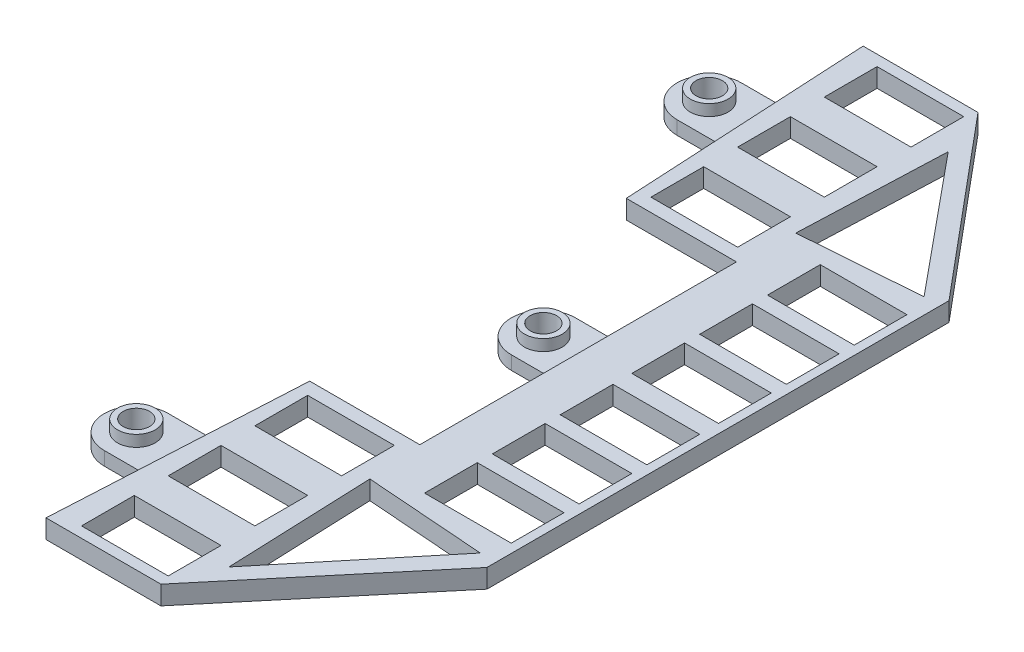
from build123d import *

# Parameters (mm, degrees)
RESSALTO_EXTRUS_O1_DEPTH         = 1.25
ESBO_O5_W                        = 11.5
ESBO_O5_H                        = 7
CORTE_EXTRUS_O1_DEPTH            = 2.5
PADR_O_LINEAR1_COUNT             = 3
PADR_O_LINEAR1_PITCH             = 9
ESBO_O8_W                        = 11.5
ESBO_O8_H                        = 7
CORTE_EXTRUS_O4_DEPTH            = 10
PADR_O_LINEAR3_COUNT             = 3
PADR_O_LINEAR3_PITCH             = 11.5
ESPELHAR1_COPY_1_SKETCH_W        = 11.5
ESPELHAR1_COPY_1_SKETCH_H        = 7
ESPELHAR1_COPY_1_DEPTH           = 10
ESPELHAR1_COPY_2_SKETCH_W        = 11.5
ESPELHAR1_COPY_2_SKETCH_H        = 7
ESPELHAR1_COPY_2_DEPTH           = 10
ESPELHAR2_COPY_1_SKETCH_W        = 11.5
ESPELHAR2_COPY_1_SKETCH_H        = 7
ESPELHAR2_COPY_1_DEPTH           = 2.5
ESPELHAR2_COPY_2_SKETCH_W        = 11.5
ESPELHAR2_COPY_2_SKETCH_H        = 7
ESPELHAR2_COPY_2_DEPTH           = 2.5
CORTE_EXTRUS_O5_DEPTH            = 10
ESBO_O10_R                       = 1.75
RESSALTO_EXTRUS_O2_DEPTH         = 0.9
ESBO_O11_R                       = 2.5
ESBO_O11_R_2                     = 1.75
RESSALTO_EXTRUS_O3_DEPTH         = 1.5
PADR_O_LINEAR4_COUNT             = 2
PADR_O_LINEAR4_PITCH             = 38
PADR_O_LINEAR4_COUNT_DIR2        = 2
PADR_O_LINEAR4_PITCH_DIR2        = 16
PADR_O_LINEAR4_COPY_1_SKETCH_R   = 2.5
PADR_O_LINEAR4_COPY_1_SKETCH_R_2 = 1.75
PADR_O_LINEAR4_COPY_1_DEPTH      = 1.5
ESPELHAR5_COPY_1_SKETCH_R        = 2.5
ESPELHAR5_COPY_1_SKETCH_R_2      = 1.75
ESPELHAR5_COPY_1_DEPTH           = 1.5


with BuildPart() as part:
    # Esboço1 → Ressalto-extrusão1 (new body, symmetric)
    with BuildSketch(Plane(origin=(0, 0, 0), x_dir=(1, 0, 0), z_dir=(0, 1, 0))):
        Polygon((-24.393815238, -54.2), (-9.15, -54.2), (10.553192421, -30.65), (10.553192421, 30.65), (-9.15, 54.2), (-24.393815238, 54.2), (-22.610275313, 21), (-8, 21), (-8, -21), (-22.610275313, -21), align=None)
    extrude(amount=RESSALTO_EXTRUS_O1_DEPTH, both=True)

    # Esboço5 → Corte-extrusão1 (cut)
    with BuildSketch(Plane(origin=(0, 1.25, 0), x_dir=(1, 0, 0), z_dir=(0, 1, 0))):
        with Locations((3.624348025, -4.75)):
            Rectangle(ESBO_O5_W, ESBO_O5_H)
    corte_extrus_o1 = extrude(amount=-CORTE_EXTRUS_O1_DEPTH, mode=Mode.SUBTRACT)

    # Padrão linear1: Corte-extrusão1 ×3
    with Locations(*[(0, 0, i * PADR_O_LINEAR1_PITCH) for i in range(1, PADR_O_LINEAR1_COUNT)]):
        add(corte_extrus_o1, mode=Mode.SUBTRACT)

    # Esboço8 → Corte-extrusão4 (cut)
    with BuildSketch(Plane(origin=(0, 1.25, 0), x_dir=(1, 0, 0), z_dir=(0, 1, 0))):
        with Locations((-15.36, 26.27)):
            Rectangle(ESBO_O8_W, ESBO_O8_H)
    corte_extrus_o4 = extrude(amount=-CORTE_EXTRUS_O4_DEPTH, mode=Mode.SUBTRACT)

    # Padrão linear3: Corte-extrusão4 ×3
    with Locations(*[(0, 0, -i * PADR_O_LINEAR3_PITCH) for i in range(1, PADR_O_LINEAR3_COUNT)]):
        add(corte_extrus_o4, mode=Mode.SUBTRACT)

    # Espelhar1: Corte-extrusão4 across plane
    add(corte_extrus_o4.mirror(Plane.XY), mode=Mode.SUBTRACT)

    # Espelhar1 copy 1 sketch → Espelhar1 copy 1 (cut)
    with BuildSketch(Plane(origin=(0, 1.25, 11.5), x_dir=(1, 0, 0), z_dir=(0, 1, 0))):
        with Locations((-15.36, -26.27)):
            Rectangle(ESPELHAR1_COPY_1_SKETCH_W, ESPELHAR1_COPY_1_SKETCH_H)
    extrude(amount=-ESPELHAR1_COPY_1_DEPTH, mode=Mode.SUBTRACT)

    # Espelhar1 copy 2 sketch → Espelhar1 copy 2 (cut)
    with BuildSketch(Plane(origin=(0, 1.25, 23), x_dir=(1, 0, 0), z_dir=(0, 1, 0))):
        with Locations((-15.36, -26.27)):
            Rectangle(ESPELHAR1_COPY_2_SKETCH_W, ESPELHAR1_COPY_2_SKETCH_H)
    extrude(amount=-ESPELHAR1_COPY_2_DEPTH, mode=Mode.SUBTRACT)

    # Espelhar2: Corte-extrusão1 across plane
    add(corte_extrus_o1.mirror(Plane.XY), mode=Mode.SUBTRACT)

    # Espelhar2 copy 1 sketch → Espelhar2 copy 1 (cut)
    with BuildSketch(Plane(origin=(0, 1.25, -9), x_dir=(1, 0, 0), z_dir=(0, 1, 0))):
        with Locations((3.624348025, 4.75)):
            Rectangle(ESPELHAR2_COPY_1_SKETCH_W, ESPELHAR2_COPY_1_SKETCH_H)
    extrude(amount=-ESPELHAR2_COPY_1_DEPTH, mode=Mode.SUBTRACT)

    # Espelhar2 copy 2 sketch → Espelhar2 copy 2 (cut)
    with BuildSketch(Plane(origin=(0, 1.25, -18), x_dir=(1, 0, 0), z_dir=(0, 1, 0))):
        with Locations((3.624348025, 4.75)):
            Rectangle(ESPELHAR2_COPY_2_SKETCH_W, ESPELHAR2_COPY_2_SKETCH_H)
    extrude(amount=-ESPELHAR2_COPY_2_DEPTH, mode=Mode.SUBTRACT)

    # Esboço9 → Corte-extrusão5 (cut)
    with BuildSketch(Plane(origin=(0, 1.25, 0), x_dir=(1, 0, 0), z_dir=(0, 1, 0))):
        Polygon((8.455719459, -29.435601452), (-7.375936588, -28.25205491), (-6.609249814, -47.710896474), align=None)
    corte_extrus_o5 = extrude(amount=-CORTE_EXTRUS_O5_DEPTH, mode=Mode.SUBTRACT)

    # Espelhar3: Corte-extrusão5 across plane
    add(corte_extrus_o5.mirror(Plane.XY), mode=Mode.SUBTRACT)

    # Esboço10 → Ressalto-extrusão2 (add, symmetric)
    with BuildSketch(Plane(origin=(0, 0, 0), x_dir=(1, 0, 0), z_dir=(0, 1, 0))):
        with BuildLine():
            Line((-28.61, -33.75), (-23.29521911, -33.75))
            Line((-23.29521911, -33.75), (-23.751848307, -42.25))
            Line((-23.751848307, -42.25), (-28.61, -42.25))
            ThreePointArc((-28.61, -42.25), (-32.86, -38), (-28.61, -33.75))
        make_face()
        with Locations((-28.61, -38)):
            Circle(ESBO_O10_R, mode=Mode.SUBTRACT)
    ressalto_extrus_o2 = extrude(amount=RESSALTO_EXTRUS_O2_DEPTH, both=True)

    # Esboço11 → Ressalto-extrusão3 (add)
    with BuildSketch(Plane(origin=(0, 0.9, 0), x_dir=(1, 0, 0), z_dir=(0, 1, 0))):
        with Locations((-28.61, -38)):
            Circle(ESBO_O11_R)
        with Locations((-28.61, -38)):
            Circle(ESBO_O11_R_2, mode=Mode.SUBTRACT)
    ressalto_extrus_o3 = extrude(amount=RESSALTO_EXTRUS_O3_DEPTH)

    # Espelhar4: Ressalto-extrusão3 across plane
    add(ressalto_extrus_o3.mirror(Plane.ZX))

    # Padrão linear4: Ressalto-extrusão2, Ressalto-extrus_o3 2 × 2, 2 skipped
    with Locations(*[(j * PADR_O_LINEAR4_PITCH_DIR2, 0, -i * PADR_O_LINEAR4_PITCH) for i in range(PADR_O_LINEAR4_COUNT) for j in range(PADR_O_LINEAR4_COUNT_DIR2) if (i, j) not in ((0, 0), (0, 1), (1, 0))]):
        add(ressalto_extrus_o2)
        add(ressalto_extrus_o3)

    # Padrão linear4 copy 1 sketch → Padrão linear4 copy 1 (add)
    with BuildSketch(Plane(origin=(16, -0.9, -38), x_dir=(1, 0, 0), z_dir=(0, -1, 0))):
        with Locations((-28.61, 38)):
            Circle(PADR_O_LINEAR4_COPY_1_SKETCH_R)
        with Locations((-28.61, 38)):
            Circle(PADR_O_LINEAR4_COPY_1_SKETCH_R_2, mode=Mode.SUBTRACT)
    extrude(amount=PADR_O_LINEAR4_COPY_1_DEPTH)

    # Espelhar5: Ressalto-extrusão3, Ressalto-extrusão2 across plane
    add(ressalto_extrus_o3.mirror(Plane.XY))
    add(ressalto_extrus_o2.mirror(Plane.XY))

    # Espelhar5 copy 1 sketch → Espelhar5 copy 1 (add)
    with BuildSketch(Plane.XZ.offset(0.9)):
        with Locations((-28.61, -38)):
            Circle(ESPELHAR5_COPY_1_SKETCH_R)
        with Locations((-28.61, -38)):
            Circle(ESPELHAR5_COPY_1_SKETCH_R_2, mode=Mode.SUBTRACT)
    extrude(amount=ESPELHAR5_COPY_1_DEPTH)


solid = part.part
